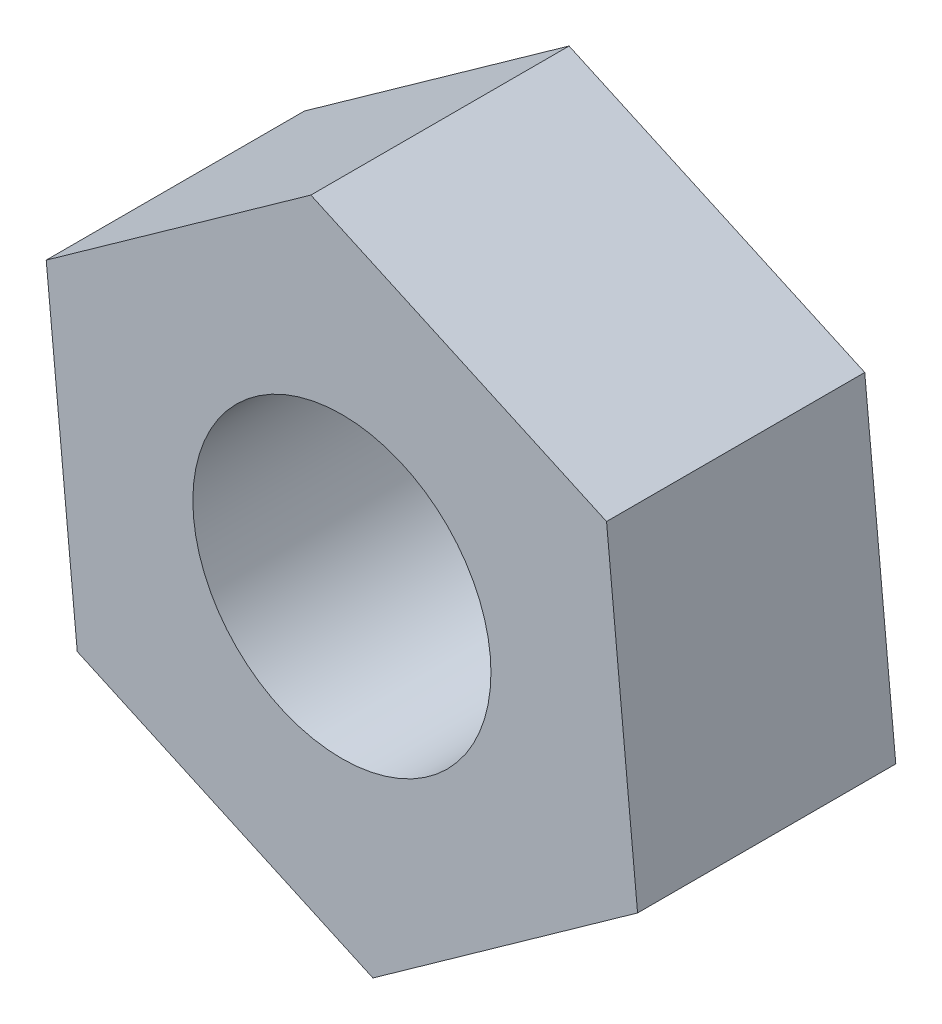
from build123d import *

# Parameters (mm, degrees)
SKETCH1_R           = 3.175
BOSS_EXTRUDE1_DEPTH = 5.5


with BuildPart() as part:
    # Sketch1 → Boss-Extrude1 (new body)
    with BuildSketch(Plane.XY):
        Polygon((-5.637061857, -4.017905792), (0.661077557, -6.890791667), (6.298139414, -2.872885875), (5.637061857, 4.017905792), (-0.661077557, 6.890791667), (-6.298139414, 2.872885875), align=None)
        Circle(SKETCH1_R, mode=Mode.SUBTRACT)
    extrude(amount=BOSS_EXTRUDE1_DEPTH)


solid = part.part
